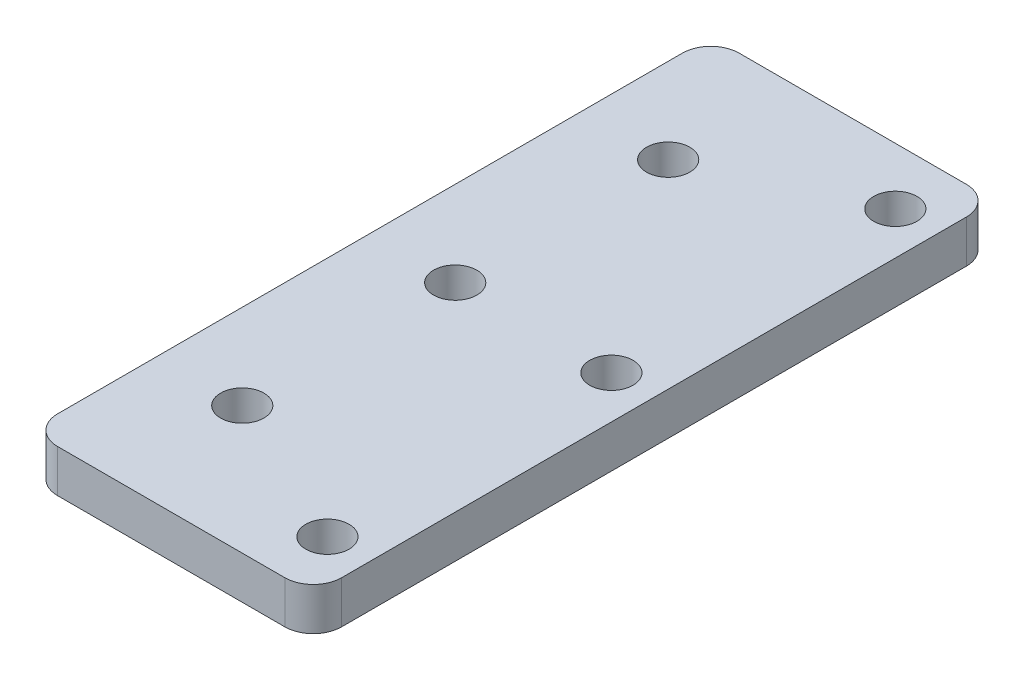
from build123d import *

# Parameters (mm, degrees)
SKETCH_1_W          = 20
SKETCH_1_H          = 48
EXTRUDE_1_DEPTH     = 3
SKETCH_2_R          = 1.525
CUT_EXTRUDE_1_DEPTH = 4
FILLET_1_R          = 2


with BuildPart() as part:
    # 草图1 → 凸台-拉伸1 (new body)
    with BuildSketch(Plane(origin=(0, 0, 0), x_dir=(1, 0, 0), z_dir=(0, 1, 0))):
        Rectangle(SKETCH_1_W, SKETCH_1_H)
    extrude(amount=EXTRUDE_1_DEPTH)

    # 草图2 → 切除-拉伸1 (cut, through all)
    with BuildSketch(Plane(origin=(0, 3, 0), x_dir=(1, 0, 0), z_dir=(0, 1, 0))):
        with Locations((7, 0)):
            Circle(SKETCH_2_R)
        with Locations((7, 20)):
            Circle(SKETCH_2_R)
        with Locations((-4, 0)):
            Circle(SKETCH_2_R)
        with Locations((-4, 15)):
            Circle(SKETCH_2_R)
        with Locations((7, -20)):
            Circle(SKETCH_2_R)
        with Locations((-4, -15)):
            Circle(SKETCH_2_R)
    extrude(amount=-CUT_EXTRUDE_1_DEPTH, mode=Mode.SUBTRACT)

    # 圆角1
    fillet_1_edges = [part.edges().sort_by_distance(p)[0] for p in [
        (10, 1.5, 24),
        (-10, 1.5, 24),
        (-10, 1.5, -24),
        (10, 1.5, -24),
    ]]
    fillet(fillet_1_edges, radius=FILLET_1_R)


solid = part.part
